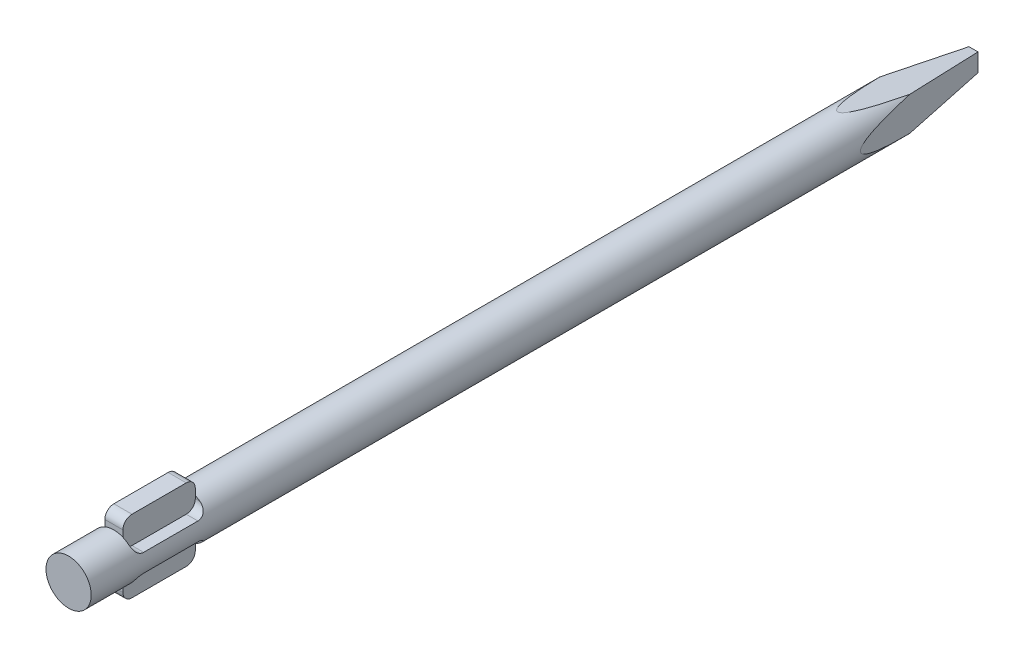
from build123d import *

# Parameters (mm, degrees)
SKETCH1_R           = 2.5
BOSS_EXTRUDE1_DEPTH = 100
CUT_EXTRUDE1_DEPTH  = 5
BOSS_EXTRUDE2_DEPTH = 1
CUT_EXTRUDE2_DEPTH  = 6
CUT_EXTRUDE3_DEPTH  = 2.5


with BuildPart() as part:
    # Sketch1 → Boss-Extrude1 (new body)
    with BuildSketch(Plane.XY):
        Circle(SKETCH1_R)
    extrude(amount=BOSS_EXTRUDE1_DEPTH)

    # Sketch2 → Cut-Extrude1 (cut, symmetric)
    with BuildSketch(Plane(origin=(0, 0, 0), x_dir=(0, 0, -1), z_dir=(1, 0, 0))):
        with BuildLine():
            Line((-94, 4), (-88, 4))
            ThreePointArc((-88, 4), (-87.292893219, 3.707106781), (-87, 3))
            Line((-87, 3), (-87, 2))
            ThreePointArc((-87, 2), (-87.292893219, 1.292893219), (-88, 1))
            Line((-88, 1), (-94, 1))
            ThreePointArc((-94, 1), (-94.707106781, 1.292893219), (-95, 2))
            Line((-95, 2), (-95, 3))
            ThreePointArc((-95, 3), (-94.707106781, 3.707106781), (-94, 4))
        make_face()
        with BuildLine():
            Line((-87, -3), (-87, -2))
            ThreePointArc((-87, -2), (-87.292893219, -1.292893219), (-88, -1))
            Line((-88, -1), (-94, -1))
            ThreePointArc((-94, -1), (-94.707106781, -1.292893219), (-95, -2))
            Line((-95, -2), (-95, -3))
            ThreePointArc((-95, -3), (-94.707106781, -3.707106781), (-94, -4))
            Line((-94, -4), (-88, -4))
            ThreePointArc((-88, -4), (-87.292893219, -3.707106781), (-87, -3))
        make_face()
    extrude(amount=CUT_EXTRUDE1_DEPTH, both=True, mode=Mode.SUBTRACT)

    # Sketch2_2 → Boss-Extrude2 (add, symmetric)
    with BuildSketch(Plane(origin=(0, 0, 0), x_dir=(0, 0, -1), z_dir=(1, 0, 0))):
        with BuildLine():
            Line((-94, 4), (-88, 4))
            ThreePointArc((-88, 4), (-87.292893219, 3.707106781), (-87, 3))
            Line((-87, 3), (-87, 2))
            ThreePointArc((-87, 2), (-87.292893219, 1.292893219), (-88, 1))
            Line((-88, 1), (-94, 1))
            ThreePointArc((-94, 1), (-94.707106781, 1.292893219), (-95, 2))
            Line((-95, 2), (-95, 3))
            ThreePointArc((-95, 3), (-94.707106781, 3.707106781), (-94, 4))
        make_face()
        with BuildLine():
            Line((-87, -3), (-87, -2))
            ThreePointArc((-87, -2), (-87.292893219, -1.292893219), (-88, -1))
            Line((-88, -1), (-94, -1))
            ThreePointArc((-94, -1), (-94.707106781, -1.292893219), (-95, -2))
            Line((-95, -2), (-95, -3))
            ThreePointArc((-95, -3), (-94.707106781, -3.707106781), (-94, -4))
            Line((-94, -4), (-88, -4))
            ThreePointArc((-88, -4), (-87.292893219, -3.707106781), (-87, -3))
        make_face()
    extrude(amount=BOSS_EXTRUDE2_DEPTH, both=True)

    # Sketch3 → Cut-Extrude2 (cut, symmetric)
    with BuildSketch(Plane(origin=(0, 0, 0), x_dir=(0, 0, -1), z_dir=(1, 0, 0))):
        Polygon((0, -2.5), (0, -1), (-15, -2.5), align=None)
        Polygon((-15, 2.5), (0, 1), (0, 2.5), align=None)
    extrude(amount=CUT_EXTRUDE2_DEPTH, both=True, mode=Mode.SUBTRACT)

    # Sketch4 → Cut-Extrude3 (cut, symmetric)
    with BuildSketch(Plane(origin=(0, 0, 0), x_dir=(1, 0, 0), z_dir=(0, 1, 0))):
        Polygon((2.5, 0), (0.5, 0), (2.5, -15), align=None)
        Polygon((-2.5, -15), (-0.5, 0), (-2.5, 0), align=None)
    extrude(amount=CUT_EXTRUDE3_DEPTH, both=True, mode=Mode.SUBTRACT)


solid = part.part
